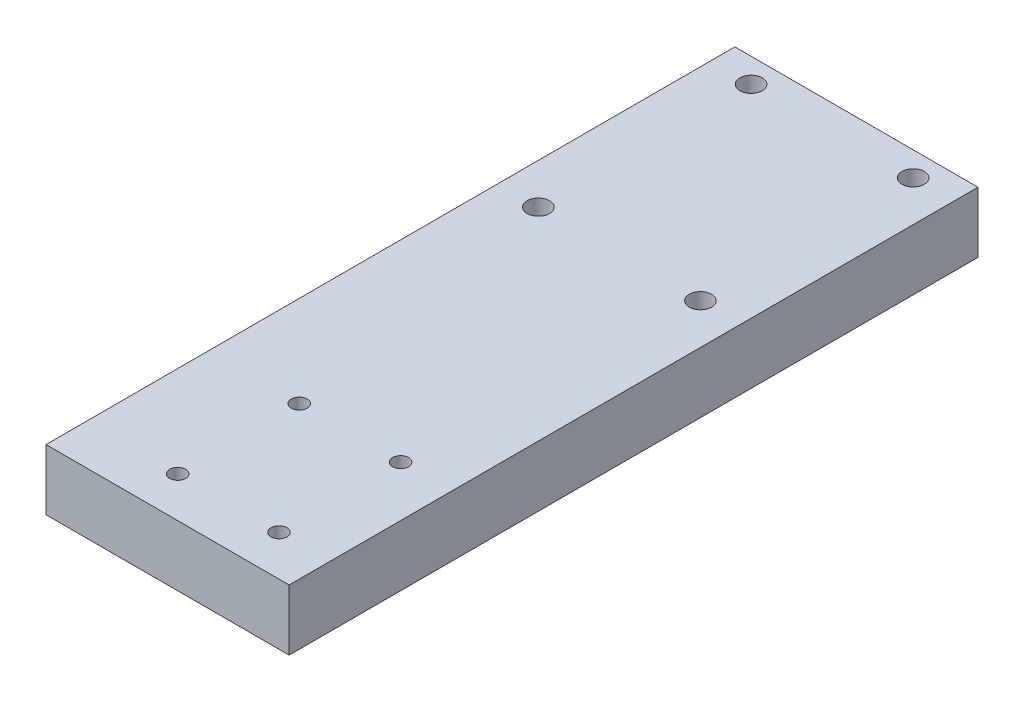
from build123d import *

# Parameters (mm, degrees)
SKETCH2_W           = 76.2
SKETCH2_H           = 19.05
BOSS_EXTRUDE1_DEPTH = 215.9
SKETCH3_R           = 3.5
CUT_EXTRUDE1_DEPTH  = 20.05
SKETCH4_R           = 2.5
CUT_EXTRUDE2_DEPTH  = 20.05


with BuildPart() as part:
    # Sketch2 → Boss-Extrude1 (new body)
    with BuildSketch(Plane.XY):
        with Locations((38.1, 9.525)):
            Rectangle(SKETCH2_W, SKETCH2_H)
    extrude(amount=BOSS_EXTRUDE1_DEPTH)

    # Sketch3 → Cut-Extrude1 (cut, through all)
    with BuildSketch(Plane(origin=(0, 19.05, 0), x_dir=(1, 0, 0), z_dir=(0, 1, 0))):
        with Locations((12.7, -7.62)):
            Circle(SKETCH3_R)
        with Locations((63.5, -7.62)):
            Circle(SKETCH3_R)
        with Locations((63.5, -74.295)):
            Circle(SKETCH3_R)
        with Locations((12.7, -74.295)):
            Circle(SKETCH3_R)
    extrude(amount=-CUT_EXTRUDE1_DEPTH, mode=Mode.SUBTRACT)

    # Sketch4 → Cut-Extrude2 (cut, through all)
    with BuildSketch(Plane(origin=(0, 19.05, 0), x_dir=(1, 0, 0), z_dir=(0, 1, 0))):
        with Locations((28.575, -203.2)):
            Circle(SKETCH4_R)
        with Locations((60.325, -203.2)):
            Circle(SKETCH4_R)
        with Locations((60.325, -165.1)):
            Circle(SKETCH4_R)
        with Locations((28.575, -165.1)):
            Circle(SKETCH4_R)
    extrude(amount=-CUT_EXTRUDE2_DEPTH, mode=Mode.SUBTRACT)


solid = part.part
